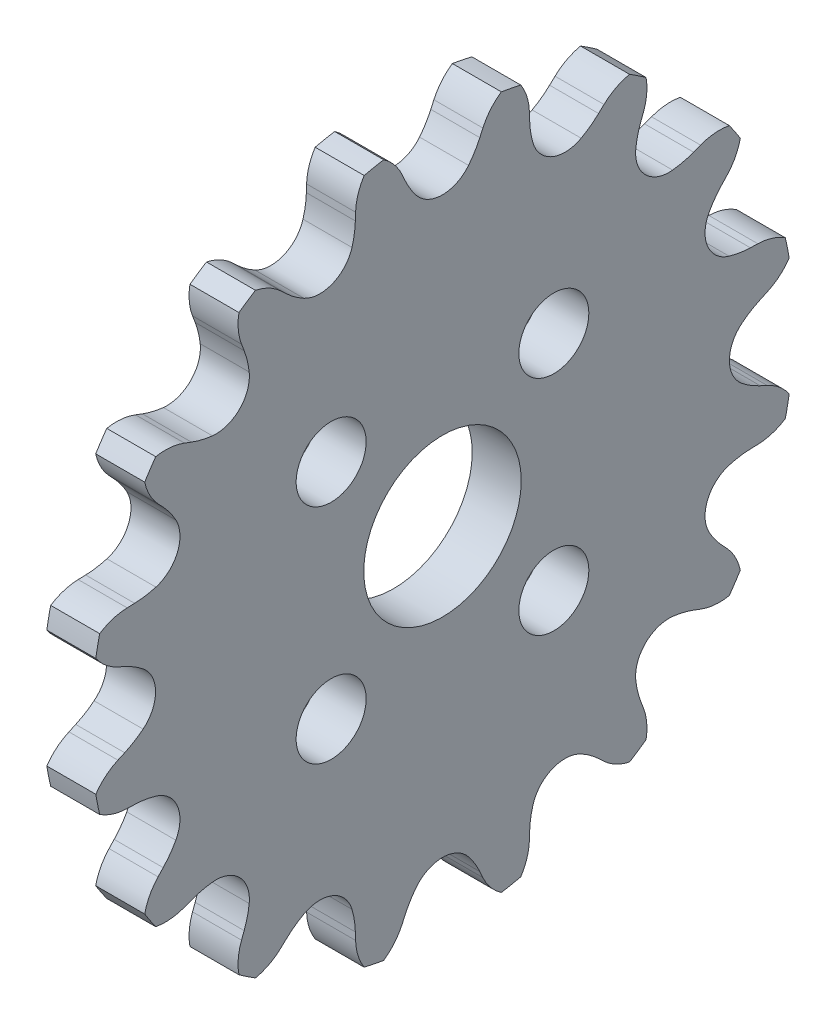
from build123d import *

# Parameters (mm, degrees)
SKETCH1_R           = 4
SKETCH1_R_2         = 1.778
BOSS_EXTRUDE1_DEPTH = 2.4892


with BuildPart() as part:
    # Sketch1 → Boss-Extrude1 (new body)
    with BuildSketch(Plane(origin=(0, 0, 0), x_dir=(0, -1, 0), z_dir=(-1, 0, 0))):
        with BuildLine():
            Line((-15.642380654, 4.427122961), (-16.020704035, 4.415564137))
            ThreePointArc((-16.020704035, 4.415564137), (-16.749265217, 4.293027867), (-17.418066441, 3.979146586))
            ThreePointArc((-17.418066441, 3.979146586), (-17.523497298, 3.485640332), (-17.614948554, 2.989353363))
            ThreePointArc((-17.614948554, 2.989353363), (-17.117173958, 2.443425725), (-16.490963794, 2.051408679))
            Line((-16.490963794, 2.051408679), (-16.145861936, 1.895951627))
            ThreePointArc((-16.145861936, 1.895951627), (-15.660854796, 1.639424454), (-15.212098776, 1.323740827))
            ThreePointArc((-15.212098776, 1.323740827), (-14.577158112, 0), (-15.212098776, -1.323740827))
            ThreePointArc((-15.212098776, -1.323740827), (-15.660854796, -1.639424454), (-16.145861936, -1.895951627))
            Line((-16.145861936, -1.895951627), (-16.490963794, -2.051408679))
            ThreePointArc((-16.490963794, -2.051408679), (-17.117173958, -2.443425725), (-17.614948554, -2.989353363))
            ThreePointArc((-17.614948554, -2.989353363), (-17.523497298, -3.485640332), (-17.418066441, -3.979146586))
            ThreePointArc((-17.418066441, -3.979146586), (-16.749265217, -4.293027867), (-16.020704035, -4.415564137))
            Line((-16.020704035, -4.415564137), (-15.642380654, -4.427122961))
            ThreePointArc((-15.642380654, -4.427122961), (-15.096123785, -4.478518969), (-14.560720389, -4.598441117))
            ThreePointArc((-14.560720389, -4.598441117), (-13.467538021, -5.5784369), (-13.547573023, -7.044395229))
            ThreePointArc((-13.547573023, -7.044395229), (-13.84136263, -7.507780365), (-14.191282102, -7.930384767))
            Line((-14.191282102, -7.930384767), (-14.450623806, -8.206073119))
            ThreePointArc((-14.450623806, -8.206073119), (-14.879148131, -8.807889899), (-15.13011443, -9.502751361))
            ThreePointArc((-15.13011443, -9.502751361), (-14.855703686, -9.926263854), (-14.569441607, -10.341857539))
            ThreePointArc((-14.569441607, -10.341857539), (-13.83143268, -10.375906881), (-13.111437314, -10.210307339))
            Line((-13.111437314, -10.210307339), (-12.757488716, -10.076208211))
            ThreePointArc((-12.757488716, -10.076208211), (-12.233144774, -9.914648477), (-11.692604316, -9.820552086))
            ThreePointArc((-11.692604316, -9.820552086), (-10.307607351, -10.307607351), (-9.820552086, -11.692604316))
            ThreePointArc((-9.820552086, -11.692604316), (-9.914648477, -12.233144774), (-10.076208211, -12.757488716))
            Line((-10.076208211, -12.757488716), (-10.210307339, -13.111437314))
            ThreePointArc((-10.210307339, -13.111437314), (-10.375906881, -13.83143268), (-10.341857539, -14.569441607))
            ThreePointArc((-10.341857539, -14.569441607), (-9.926263854, -14.855703686), (-9.502751361, -15.13011443))
            ThreePointArc((-9.502751361, -15.13011443), (-8.807889899, -14.879148131), (-8.206073119, -14.450623806))
            Line((-8.206073119, -14.450623806), (-7.930384767, -14.191282102))
            ThreePointArc((-7.930384767, -14.191282102), (-7.507780365, -13.84136263), (-7.044395229, -13.547573023))
            ThreePointArc((-7.044395229, -13.547573023), (-5.5784369, -13.467538021), (-4.598441117, -14.560720389))
            ThreePointArc((-4.598441117, -14.560720389), (-4.478518969, -15.096123785), (-4.427122961, -15.642380654))
            Line((-4.427122961, -15.642380654), (-4.415564137, -16.020704035))
            ThreePointArc((-4.415564137, -16.020704035), (-4.293027867, -16.749265217), (-3.979146586, -17.418066441))
            ThreePointArc((-3.979146586, -17.418066441), (-3.485640332, -17.523497298), (-2.989353363, -17.614948554))
            ThreePointArc((-2.989353363, -17.614948554), (-2.443425725, -17.117173958), (-2.051408679, -16.490963794))
            Line((-2.051408679, -16.490963794), (-1.895951627, -16.145861936))
            ThreePointArc((-1.895951627, -16.145861936), (-1.639424454, -15.660854796), (-1.323740827, -15.212098776))
            ThreePointArc((-1.323740827, -15.212098776), (0, -14.577158112), (1.323740827, -15.212098776))
            ThreePointArc((1.323740827, -15.212098776), (1.639424454, -15.660854796), (1.895951627, -16.145861936))
            Line((1.895951627, -16.145861936), (2.051408679, -16.490963794))
            ThreePointArc((2.051408679, -16.490963794), (2.443425725, -17.117173958), (2.989353363, -17.614948554))
            ThreePointArc((2.989353363, -17.614948554), (3.485640332, -17.523497298), (3.979146586, -17.418066441))
            ThreePointArc((3.979146586, -17.418066441), (4.293027867, -16.749265217), (4.415564137, -16.020704035))
            Line((4.415564137, -16.020704035), (4.427122961, -15.642380654))
            ThreePointArc((4.427122961, -15.642380654), (4.478518969, -15.096123785), (4.598441117, -14.560720389))
            ThreePointArc((4.598441117, -14.560720389), (5.5784369, -13.467538021), (7.044395229, -13.547573023))
            ThreePointArc((7.044395229, -13.547573023), (7.507780365, -13.84136263), (7.930384767, -14.191282102))
            Line((7.930384767, -14.191282102), (8.206073119, -14.450623806))
            ThreePointArc((8.206073119, -14.450623806), (8.807889899, -14.879148131), (9.502751361, -15.13011443))
            ThreePointArc((9.502751361, -15.13011443), (9.926263854, -14.855703686), (10.341857539, -14.569441607))
            ThreePointArc((10.341857539, -14.569441607), (10.375906881, -13.83143268), (10.210307339, -13.111437314))
            Line((10.210307339, -13.111437314), (10.076208211, -12.757488716))
            ThreePointArc((10.076208211, -12.757488716), (9.914648477, -12.233144774), (9.820552086, -11.692604316))
            ThreePointArc((9.820552086, -11.692604316), (10.307607351, -10.307607351), (11.692604316, -9.820552086))
            ThreePointArc((11.692604316, -9.820552086), (12.233144774, -9.914648477), (12.757488716, -10.076208211))
            Line((12.757488716, -10.076208211), (13.111437314, -10.210307339))
            ThreePointArc((13.111437314, -10.210307339), (13.83143268, -10.375906881), (14.569441607, -10.341857539))
            ThreePointArc((14.569441607, -10.341857539), (14.855703686, -9.926263854), (15.13011443, -9.502751361))
            ThreePointArc((15.13011443, -9.502751361), (14.879148131, -8.807889899), (14.450623806, -8.206073119))
            Line((14.450623806, -8.206073119), (14.191282102, -7.930384767))
            ThreePointArc((14.191282102, -7.930384767), (13.84136263, -7.507780365), (13.547573023, -7.044395229))
            ThreePointArc((13.547573023, -7.044395229), (13.467538021, -5.5784369), (14.560720389, -4.598441117))
            ThreePointArc((14.560720389, -4.598441117), (15.096123785, -4.478518969), (15.642380654, -4.427122961))
            Line((15.642380654, -4.427122961), (16.020704035, -4.415564137))
            ThreePointArc((16.020704035, -4.415564137), (16.749265217, -4.293027867), (17.418066441, -3.979146586))
            ThreePointArc((17.418066441, -3.979146586), (17.523497298, -3.485640332), (17.614948554, -2.989353363))
            ThreePointArc((17.614948554, -2.989353363), (17.117173958, -2.443425725), (16.490963794, -2.051408679))
            Line((16.490963794, -2.051408679), (16.145861936, -1.895951627))
            ThreePointArc((16.145861936, -1.895951627), (15.660854796, -1.639424454), (15.212098776, -1.323740827))
            ThreePointArc((15.212098776, -1.323740827), (14.577158112, 0), (15.212098776, 1.323740827))
            ThreePointArc((15.212098776, 1.323740827), (15.660854796, 1.639424454), (16.145861936, 1.895951627))
            Line((16.145861936, 1.895951627), (16.490963794, 2.051408679))
            ThreePointArc((16.490963794, 2.051408679), (17.117173958, 2.443425725), (17.614948554, 2.989353363))
            ThreePointArc((17.614948554, 2.989353363), (17.523497298, 3.485640332), (17.418066441, 3.979146586))
            ThreePointArc((17.418066441, 3.979146586), (16.749265217, 4.293027867), (16.020704035, 4.415564137))
            Line((16.020704035, 4.415564137), (15.642380654, 4.427122961))
            ThreePointArc((15.642380654, 4.427122961), (15.096123785, 4.478518969), (14.560720389, 4.598441117))
            ThreePointArc((14.560720389, 4.598441117), (13.467538021, 5.5784369), (13.547573023, 7.044395229))
            ThreePointArc((13.547573023, 7.044395229), (13.84136263, 7.507780365), (14.191282102, 7.930384767))
            Line((14.191282102, 7.930384767), (14.450623806, 8.206073119))
            ThreePointArc((14.450623806, 8.206073119), (14.879148131, 8.807889899), (15.13011443, 9.502751361))
            ThreePointArc((15.13011443, 9.502751361), (14.855703686, 9.926263854), (14.569441607, 10.341857539))
            ThreePointArc((14.569441607, 10.341857539), (13.83143268, 10.375906881), (13.111437314, 10.210307339))
            Line((13.111437314, 10.210307339), (12.757488716, 10.076208211))
            ThreePointArc((12.757488716, 10.076208211), (12.233144774, 9.914648477), (11.692604316, 9.820552086))
            ThreePointArc((11.692604316, 9.820552086), (10.307607351, 10.307607351), (9.820552086, 11.692604316))
            ThreePointArc((9.820552086, 11.692604316), (9.914648477, 12.233144774), (10.076208211, 12.757488716))
            Line((10.076208211, 12.757488716), (10.210307339, 13.111437314))
            ThreePointArc((10.210307339, 13.111437314), (10.375906881, 13.83143268), (10.341857539, 14.569441607))
            ThreePointArc((10.341857539, 14.569441607), (9.926263854, 14.855703686), (9.502751361, 15.13011443))
            ThreePointArc((9.502751361, 15.13011443), (8.807889899, 14.879148131), (8.206073119, 14.450623806))
            Line((8.206073119, 14.450623806), (7.930384767, 14.191282102))
            ThreePointArc((7.930384767, 14.191282102), (7.507780365, 13.84136263), (7.044395229, 13.547573023))
            ThreePointArc((7.044395229, 13.547573023), (5.5784369, 13.467538021), (4.598441117, 14.560720389))
            ThreePointArc((4.598441117, 14.560720389), (4.478518969, 15.096123785), (4.427122961, 15.642380654))
            Line((4.427122961, 15.642380654), (4.415564137, 16.020704035))
            ThreePointArc((4.415564137, 16.020704035), (4.293027867, 16.749265217), (3.979146586, 17.418066441))
            ThreePointArc((3.979146586, 17.418066441), (3.485640332, 17.523497298), (2.989353363, 17.614948554))
            ThreePointArc((2.989353363, 17.614948554), (2.443425725, 17.117173958), (2.051408679, 16.490963794))
            Line((2.051408679, 16.490963794), (1.895951627, 16.145861936))
            ThreePointArc((1.895951627, 16.145861936), (1.639424454, 15.660854796), (1.323740827, 15.212098776))
            ThreePointArc((1.323740827, 15.212098776), (0, 14.577158112), (-1.323740827, 15.212098776))
            ThreePointArc((-1.323740827, 15.212098776), (-1.639424454, 15.660854796), (-1.895951627, 16.145861936))
            Line((-1.895951627, 16.145861936), (-2.051408679, 16.490963794))
            ThreePointArc((-2.051408679, 16.490963794), (-2.443425725, 17.117173958), (-2.989353363, 17.614948554))
            ThreePointArc((-2.989353363, 17.614948554), (-3.485640332, 17.523497298), (-3.979146586, 17.418066441))
            ThreePointArc((-3.979146586, 17.418066441), (-4.293027867, 16.749265217), (-4.415564137, 16.020704035))
            Line((-4.415564137, 16.020704035), (-4.427122961, 15.642380654))
            ThreePointArc((-4.427122961, 15.642380654), (-4.478518969, 15.096123785), (-4.598441117, 14.560720389))
            ThreePointArc((-4.598441117, 14.560720389), (-5.5784369, 13.467538021), (-7.044395229, 13.547573023))
            ThreePointArc((-7.044395229, 13.547573023), (-7.507780365, 13.84136263), (-7.930384767, 14.191282102))
            Line((-7.930384767, 14.191282102), (-8.206073119, 14.450623806))
            ThreePointArc((-8.206073119, 14.450623806), (-8.807889899, 14.879148131), (-9.502751361, 15.13011443))
            ThreePointArc((-9.502751361, 15.13011443), (-9.926263854, 14.855703686), (-10.341857539, 14.569441607))
            ThreePointArc((-10.341857539, 14.569441607), (-10.375906881, 13.83143268), (-10.210307339, 13.111437314))
            Line((-10.210307339, 13.111437314), (-10.076208211, 12.757488716))
            ThreePointArc((-10.076208211, 12.757488716), (-9.914648477, 12.233144774), (-9.820552086, 11.692604316))
            ThreePointArc((-9.820552086, 11.692604316), (-10.307607351, 10.307607351), (-11.692604316, 9.820552086))
            ThreePointArc((-11.692604316, 9.820552086), (-12.233144774, 9.914648477), (-12.757488716, 10.076208211))
            Line((-12.757488716, 10.076208211), (-13.111437314, 10.210307339))
            ThreePointArc((-13.111437314, 10.210307339), (-13.83143268, 10.375906881), (-14.569441607, 10.341857539))
            ThreePointArc((-14.569441607, 10.341857539), (-14.855703686, 9.926263854), (-15.13011443, 9.502751361))
            ThreePointArc((-15.13011443, 9.502751361), (-14.879148131, 8.807889899), (-14.450623806, 8.206073119))
            Line((-14.450623806, 8.206073119), (-14.191282102, 7.930384767))
            ThreePointArc((-14.191282102, 7.930384767), (-13.84136263, 7.507780365), (-13.547573023, 7.044395229))
            ThreePointArc((-13.547573023, 7.044395229), (-13.467538021, 5.5784369), (-14.560720389, 4.598441117))
            ThreePointArc((-14.560720389, 4.598441117), (-15.096123785, 4.478518969), (-15.642380654, 4.427122961))
        make_face()
        Circle(SKETCH1_R, mode=Mode.SUBTRACT)
        with Locations((-5.656854249, -5.656854249)):
            Circle(SKETCH1_R_2, mode=Mode.SUBTRACT)
        with Locations((-5.656854249, 5.656854249)):
            Circle(SKETCH1_R_2, mode=Mode.SUBTRACT)
        with Locations((5.656854249, 5.656854249)):
            Circle(SKETCH1_R_2, mode=Mode.SUBTRACT)
        with Locations((5.656854249, -5.656854249)):
            Circle(SKETCH1_R_2, mode=Mode.SUBTRACT)
    extrude(amount=-BOSS_EXTRUDE1_DEPTH)


solid = part.part
